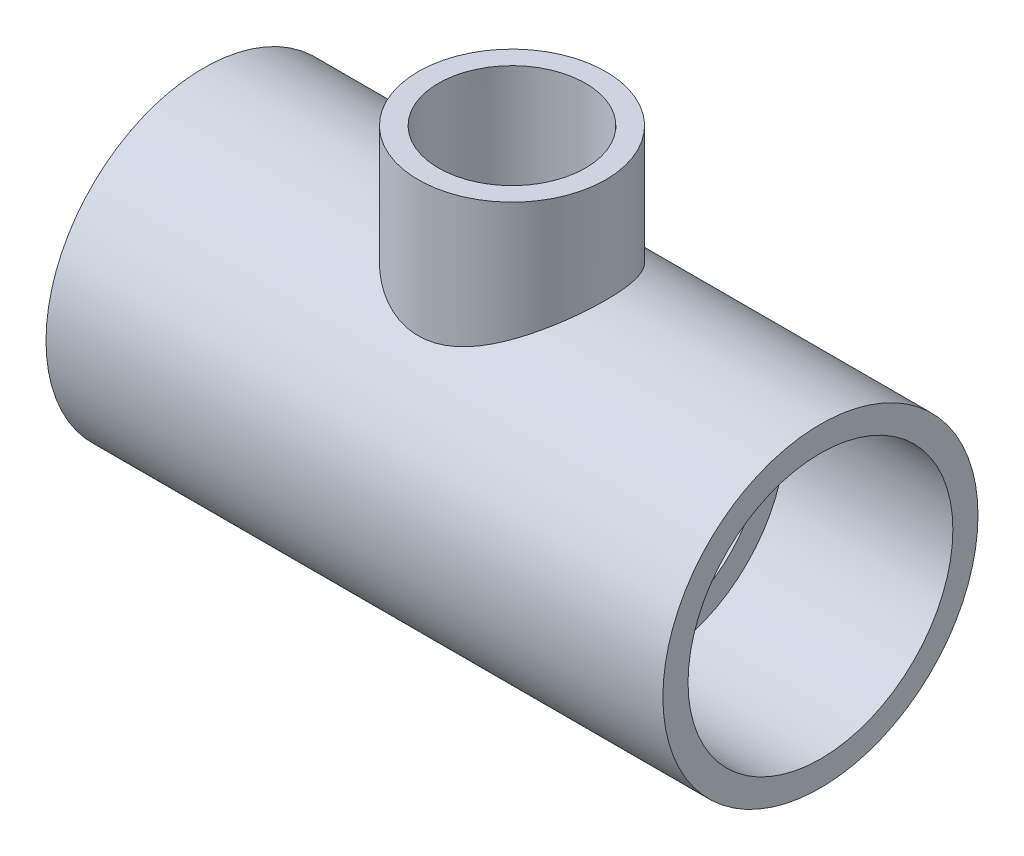
from build123d import *

# Parameters (mm, degrees)
SKETCH4_R           = 36.068
BOSS_EXTRUDE1_DEPTH = 65.024
SKETCH5_R           = 21.463
BOSS_EXTRUDE2_DEPTH = 31.369


with BuildPart() as part:
    # Sketch1 → Revolve1 (revolve)
    with BuildSketch(Plane.XY, mode=Mode.PRIVATE) as revolve1_sk:
        Polygon((-70.612, -36.068), (-32.512, -36.068), (-32.512, -30.0863), (-70.612, -30.3149), align=None)
        Polygon((70.612, -30.3149), (32.512, -30.0863), (32.512, -36.068), (70.612, -36.068), align=None)
    revolve(revolve1_sk.sketch.rotate(Axis((-70.612, 0, 0), (1, 0, 0)), 270), axis=Axis((-70.612, 0, 0), (1, 0, 0)))



with BuildPart() as body_2:
    # Sketch2 → Revolve2 (revolve)
    with BuildSketch(Plane.XY):
        Polygon((16.8275, 59.944), (16.637, 31.369), (21.463, 31.369), (21.463, 59.944), align=None)
    revolve(axis=Axis((0, 0, 0), (0, 1, 0)))


with BuildPart() as part_1:
    add(part.part)

    add(body_2.part)  # Boss-Extrude1 merges body 2
    # Sketch4 → Boss-Extrude1 (add)
    with BuildSketch(Plane(origin=(-32.512, 0, 0), x_dir=(0, 0, -1), z_dir=(1, 0, 0))):
        with Locations(Location((0, 0, 0), (0, 0, 180))):
            Circle(SKETCH4_R)
    extrude(amount=BOSS_EXTRUDE1_DEPTH)

    # Sketch5 → Boss-Extrude2 (add)
    with BuildSketch(Plane.XZ.offset(-31.369)):
        Circle(SKETCH5_R)
    extrude(amount=BOSS_EXTRUDE2_DEPTH)

    # Sketch6 → Cut-Revolve1 (revolve, cut)
    with BuildSketch(Plane.XY, mode=Mode.PRIVATE) as cut_revolve1_sk:
        Polygon((-70.612, -30.3149), (-32.512, -30.0863), (-32.512, -24.6253), (32.512, -24.6253), (32.512, -30.0863), (70.612, -30.3149), (70.612, 0), (-70.612, 0), align=None)
    revolve(cut_revolve1_sk.sketch.rotate(Axis((70.612, 0, 0), (-1, 0, 0)), 270), axis=Axis((70.612, 0, 0), (-1, 0, 0)), mode=Mode.SUBTRACT)

    # Sketch7 → Cut-Revolve2 (revolve, cut)
    with BuildSketch(Plane.XY):
        Polygon((16.8275, 59.944), (16.637, 31.369), (12.1539, 31.369), (12.1539, 0), (0, 0), (0, 59.944), align=None)
    revolve(axis=Axis((0, 0, 0), (0, 1, 0)), mode=Mode.SUBTRACT)


solid = part_1.part
